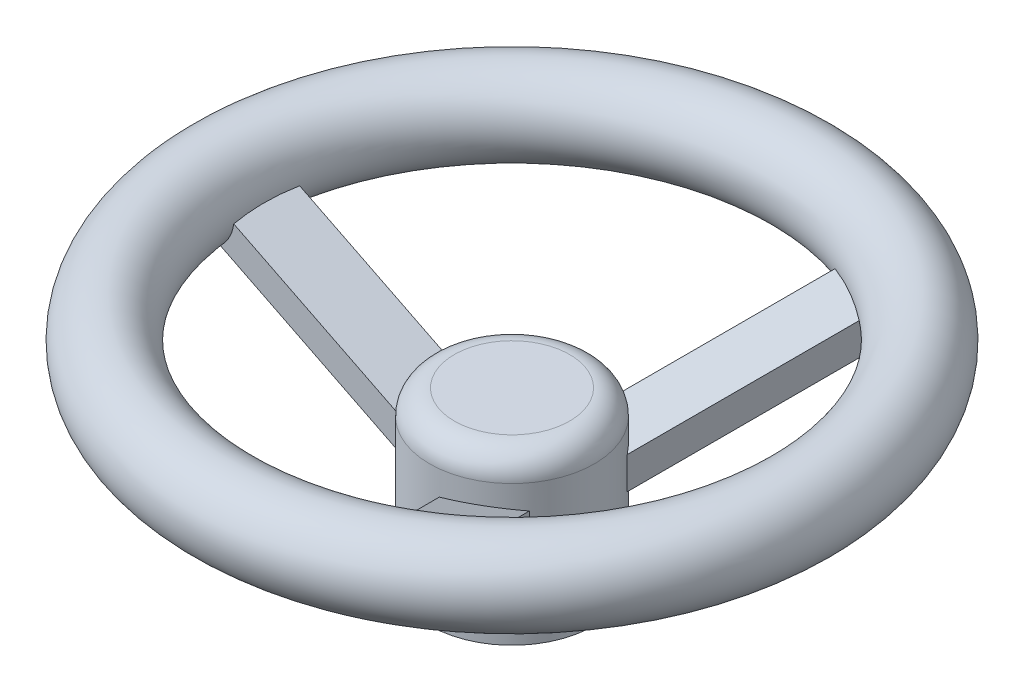
from build123d import *

# Parameters (mm, degrees)
SKETCH1_R                = 20
BOSS_EXTRUDE1_DEPTH      = 40
SKETCH1_7_R              = 8
CUT_EXTRUDE4_DEPTH       = 22
SKETCH3_R                = 10
BOSS_EXTRUDE2_REACH      = 179.2
BOSS_EXTRUDE2_END_RADIUS = 20
SKETCH6_W                = 16
SKETCH6_H                = 7
CIRPATTERN1_COUNT        = 3
FILLET1_R                = 6


with BuildPart() as part:
    # Sketch1 → Boss-Extrude1 (new body)
    with BuildSketch(Plane(origin=(0, 0, 0), x_dir=(1, 0, 0), z_dir=(0, 1, 0))):
        Circle(SKETCH1_R)
    extrude(amount=BOSS_EXTRUDE1_DEPTH)

    # Sketch1_7 → Cut-Extrude4 (cut)
    with BuildSketch(Plane(origin=(0, 0, 0), x_dir=(1, 0, 0), z_dir=(0, 1, 0))):
        Circle(SKETCH1_7_R)
    extrude(amount=CUT_EXTRUDE4_DEPTH, mode=Mode.SUBTRACT)



with BuildPart() as body_2:
    # Sketch3 → Revolve1 (revolve)
    with BuildSketch(Plane.XY):
        with Locations((-70, 50)):
            Circle(SKETCH3_R)
    revolve(axis=Axis((0, 40, 0), (0, 1, 0)))


with BuildPart() as part_1:
    add(part.part)

    add(body_2.part)  # Boss-Extrude2 merges body 2
    # Boss-Extrude2: up to this cylinder (the profile starts outside it)
    boss_extrude2_end = Plane(origin=(0, 50, 0), z_dir=(0, -1, 0)) * Cylinder(BOSS_EXTRUDE2_END_RADIUS, 399.4, mode=Mode.PRIVATE)
    # Sketch6 → Boss-Extrude2 (add, up to the surface)
    with BuildSketch(Plane(origin=(-70, 50, 0), x_dir=(0, 0, 1), z_dir=(-0.8944271909999159, 0.44721359549995815, 0)), mode=Mode.PRIVATE) as boss_extrude2_sk1:
        Rectangle(SKETCH6_W, SKETCH6_H)
    boss_extrude2_tool1 = extrude(boss_extrude2_sk1.sketch, amount=-BOSS_EXTRUDE2_REACH, mode=Mode.PRIVATE) - boss_extrude2_end
    boss_extrude2 = boss_extrude2_tool1.solids().sort_by_distance((-70, 50, 0))[0]
    add(boss_extrude2)

    # CirPattern1: Boss-Extrude2 ×3 about axis
    cirpattern1_axis = Axis((0, 40, 0), (0, 1, 0))
    for i in range(1, CIRPATTERN1_COUNT):
        add(boss_extrude2.rotate(cirpattern1_axis, i * 360 / CIRPATTERN1_COUNT))

    # Fillet1
    fillet1_edges = [part_1.edges().sort_by_distance(p)[0] for p in [
        (-20, 40, 0),
    ]]
    fillet(fillet1_edges, radius=FILLET1_R)


solid = part_1.part
